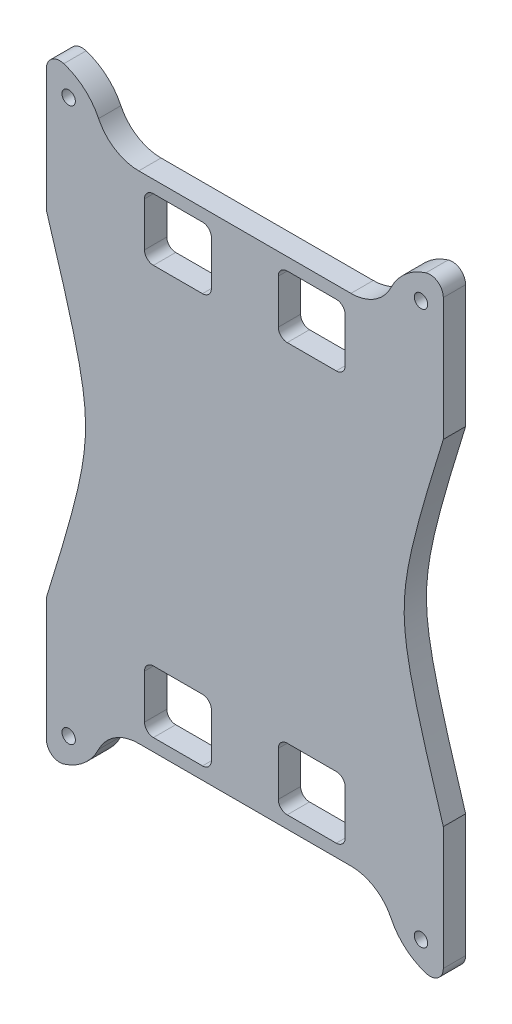
from build123d import *

# Parameters (mm, degrees)
RESSALTO_EXTRUS_O3_DEPTH = 5
ESBO_O4_R                = 1.5
CORTE_EXTRUS_O3_DEPTH    = 10


with BuildPart() as part:
    # Esboço1 → Ressalto-extrusão3 (new body)
    with BuildSketch(Plane.XY):
        with BuildLine():
            Line((-31.851570772, -17.801096987), (-27.063885949, -17.801096987))
            Line((-27.063885949, -17.801096987), (10.936114051, -17.801096987))
            Line((10.936114051, -17.801096987), (15.723798874, -17.801096987))
            ThreePointArc((15.723798874, -17.801096987), (21.039894205, -19.331201448), (24.729153299, -23.4532709))
            ThreePointArc((24.729153299, -23.4532709), (27.934250919, -27.635644423), (32.536114051, -30.202306605))
            ThreePointArc((32.536114051, -30.202306605), (35.210937986, -29.759166326), (36.436114051, -27.340489001))
            Line((36.436114051, -27.340489001), (36.436114051, -17.801096987))
            Line((36.436114051, -17.801096987), (36.436114051, 0.198903013))
            add(Edge.make_bspline(
                [(36.436114051, 75.398903013), (24.729153299, 37.798903013), (36.436114051, 0.198903013)],
                knots=[0, 0, 0, 1, 1, 1], degree=2, weights=[1, 3, 1]))
            Line((36.436114051, 75.398903013), (36.436114051, 93.398903013))
            Line((36.436114051, 93.398903013), (36.436114051, 102.938295027))
            ThreePointArc((36.436114051, 102.938295027), (35.210937986, 105.356972352), (32.536114051, 105.800112631))
            ThreePointArc((32.536114051, 105.800112631), (27.934250919, 103.23345045), (24.729153299, 99.051076926))
            ThreePointArc((24.729153299, 99.051076926), (21.039894205, 94.929007474), (15.723798874, 93.398903013))
            Line((15.723798874, 93.398903013), (10.936114051, 93.398903013))
            Line((10.936114051, 93.398903013), (-27.063885949, 93.398903013))
            Line((-27.063885949, 93.398903013), (-31.851570772, 93.398903013))
            ThreePointArc((-31.851570772, 93.398903013), (-37.167666102, 94.929007474), (-40.856925197, 99.051076926))
            ThreePointArc((-40.856925197, 99.051076926), (-44.062022817, 103.23345045), (-48.663885949, 105.800112631))
            ThreePointArc((-48.663885949, 105.800112631), (-51.338709884, 105.356972352), (-52.563885949, 102.938295027))
            Line((-52.563885949, 102.938295027), (-52.563885949, 93.398903013))
            Line((-52.563885949, 93.398903013), (-52.563885949, 75.398903013))
            add(Edge.make_bspline(
                [(-52.563885949, 75.398903013), (-40.856925197, 37.798903013), (-52.563885949, 0.198903013)],
                knots=[0, 0, 0, 1, 1, 1], degree=2, weights=[1, 3, 1]))
            Line((-52.563885949, 0.198903013), (-52.563885949, -17.801096987))
            Line((-52.563885949, -17.801096987), (-52.563885949, -27.340489001))
            ThreePointArc((-52.563885949, -27.340489001), (-51.338709884, -29.759166326), (-48.663885949, -30.202306605))
            ThreePointArc((-48.663885949, -30.202306605), (-44.062022817, -27.635644423), (-40.856925197, -23.4532709))
            ThreePointArc((-40.856925197, -23.4532709), (-37.167666102, -19.331201448), (-31.851570772, -17.801096987))
        make_face()
    extrude(amount=RESSALTO_EXTRUS_O3_DEPTH)

    # Esboço4 → Corte-extrusão3 (cut)
    with BuildSketch(Plane(origin=(0, 0, 0), x_dir=(-1, 0, 0), z_dir=(0, 0, -1))):
        with Locations((-31.436114051, 99.800112631)):
            Circle(ESBO_O4_R)
        with Locations((47.563885949, 99.800112631)):
            Circle(ESBO_O4_R)
        with Locations((47.563885949, -24.202306605)):
            Circle(ESBO_O4_R)
        with Locations((-31.436114051, -24.202306605)):
            Circle(ESBO_O4_R)
        with BuildLine():
            Line((-12.436114051, 90.598903013), (-1.436114051, 90.598903013))
            ThreePointArc((-1.436114051, 90.598903013), (-0.021900489, 90.013116575), (0.563885949, 88.598903013))
            Line((0.563885949, 88.598903013), (0.563885949, 78.698903013))
            ThreePointArc((0.563885949, 78.698903013), (-0.021900489, 77.284689451), (-1.436114051, 76.698903013))
            Line((-1.436114051, 76.698903013), (-12.436114051, 76.698903013))
            ThreePointArc((-12.436114051, 76.698903013), (-13.850327613, 77.284689451), (-14.436114051, 78.698903013))
            Line((-14.436114051, 78.698903013), (-14.436114051, 88.598903013))
            ThreePointArc((-14.436114051, 88.598903013), (-13.850327613, 90.013116575), (-12.436114051, 90.598903013))
        make_face()
        with BuildLine():
            Line((17.563885949, 90.598903013), (28.563885949, 90.598903013))
            ThreePointArc((28.563885949, 90.598903013), (29.978099511, 90.013116575), (30.563885949, 88.598903013))
            Line((30.563885949, 88.598903013), (30.563885949, 78.698903013))
            ThreePointArc((30.563885949, 78.698903013), (29.978099511, 77.284689451), (28.563885949, 76.698903013))
            Line((28.563885949, 76.698903013), (17.563885949, 76.698903013))
            ThreePointArc((17.563885949, 76.698903013), (16.149672387, 77.284689451), (15.563885949, 78.698903013))
            Line((15.563885949, 78.698903013), (15.563885949, 88.598903013))
            ThreePointArc((15.563885949, 88.598903013), (16.149672387, 90.013116575), (17.563885949, 90.598903013))
        make_face()
        with BuildLine():
            Line((30.563885949, -13.001096987), (30.563885949, -3.101096987))
            ThreePointArc((30.563885949, -3.101096987), (29.978099511, -1.686883425), (28.563885949, -1.101096987))
            Line((28.563885949, -1.101096987), (17.563885949, -1.101096987))
            ThreePointArc((17.563885949, -1.101096987), (16.149672387, -1.686883425), (15.563885949, -3.101096987))
            Line((15.563885949, -3.101096987), (15.563885949, -13.001096987))
            ThreePointArc((15.563885949, -13.001096987), (16.149672387, -14.415310549), (17.563885949, -15.001096987))
            Line((17.563885949, -15.001096987), (28.563885949, -15.001096987))
            ThreePointArc((28.563885949, -15.001096987), (29.978099511, -14.415310549), (30.563885949, -13.001096987))
        make_face()
        with BuildLine():
            Line((0.563885949, -13.001096987), (0.563885949, -3.101096987))
            ThreePointArc((0.563885949, -3.101096987), (-0.021900489, -1.686883425), (-1.436114051, -1.101096987))
            Line((-1.436114051, -1.101096987), (-12.436114051, -1.101096987))
            ThreePointArc((-12.436114051, -1.101096987), (-13.850327613, -1.686883425), (-14.436114051, -3.101096987))
            Line((-14.436114051, -3.101096987), (-14.436114051, -13.001096987))
            ThreePointArc((-14.436114051, -13.001096987), (-13.850327613, -14.415310549), (-12.436114051, -15.001096987))
            Line((-12.436114051, -15.001096987), (-1.436114051, -15.001096987))
            ThreePointArc((-1.436114051, -15.001096987), (-0.021900489, -14.415310549), (0.563885949, -13.001096987))
        make_face()
    extrude(amount=-CORTE_EXTRUS_O3_DEPTH, mode=Mode.SUBTRACT)


solid = part.part
